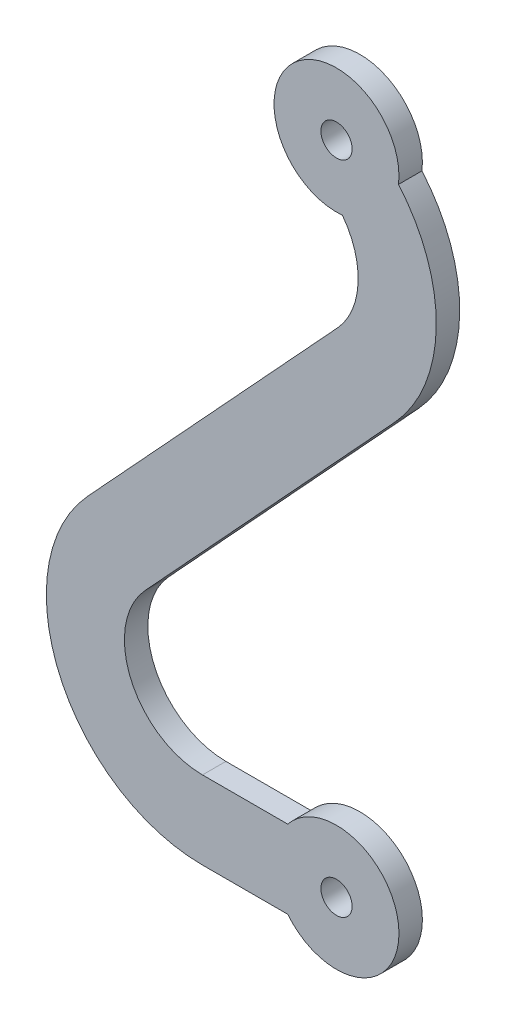
from build123d import *

# Parameters (mm, degrees)
SKETCH1_R           = 1
BOSS_EXTRUDE1_DEPTH = 1.5


with BuildPart() as part:
    # Sketch1 → Boss-Extrude1 (new body)
    with BuildSketch(Plane.XY):
        with BuildLine():
            Line((-3.122498999, 2.5), (-8.582047484, 2.5))
            ThreePointArc((-8.582047484, 2.5), (-13.162149565, 5.494341772), (-12.256495253, 10.89093403))
            Line((-12.256495253, 10.89093403), (3.737859555, 28.222566206))
            ThreePointArc((3.737859555, 28.222566206), (6.38742077, 34.828756828), (3.971570907, 41.523949028))
            ThreePointArc((3.971570907, 41.523949028), (-2.793624676, 44.86280652), (0.378773293, 38.017974034))
            ThreePointArc((0.378773293, 38.017974034), (1.382913373, 34.75852813), (0.063411786, 31.613500235))
            Line((0.063411786, 31.613500235), (-15.930943021, 14.281868059))
            ThreePointArc((-15.930943021, 14.281868059), (-17.742251646, 3.488683545), (-8.582047484, -2.5))
            Line((-8.582047484, -2.5), (-3.122498999, -2.5))
            ThreePointArc((-3.122498999, -2.5), (4, 0), (-3.122498999, 2.5))
        make_face()
        Circle(SKETCH1_R, mode=Mode.SUBTRACT)
        with Locations((0, 42)):
            Circle(SKETCH1_R, mode=Mode.SUBTRACT)
    extrude(amount=BOSS_EXTRUDE1_DEPTH)


solid = part.part
